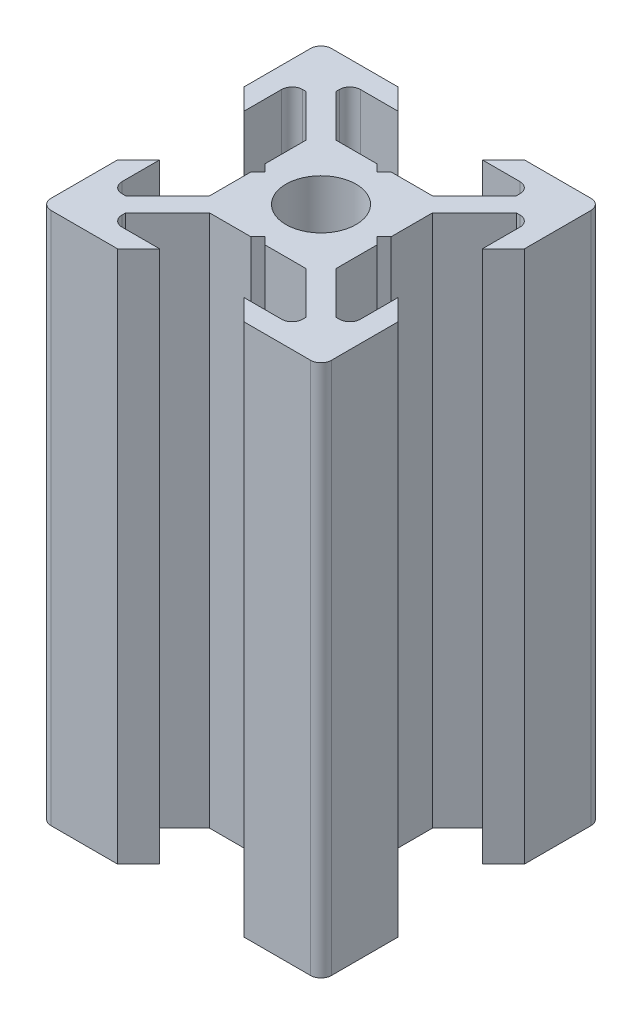
from build123d import *

# Parameters (mm, degrees)
ESQUISSE1_R      = 2.5
EXTRUSION1_DEPTH = 38
CONG_1_R         = 0.75


with BuildPart() as part:
    # Esquisse1 → Extrusion1 (new body)
    with BuildSketch(Plane(origin=(0, 0, 0), x_dir=(1, 0, 0), z_dir=(0, 1, 0))):
        Polygon((0, 4), (-0.5, 4.5), (-3.439339828, 4.5), (-6.439339828, 7.5), (-6.439339828, 8.5), (-3, 8.5), (-4.5, 10), (-10, 10), (-10, 4.5), (-8.5, 3), (-8.5, 6.439339828), (-7.5, 6.439339828), (-4.5, 3.439339828), (-4.5, 0.5), (-4, 0), (-4.5, -0.5), (-4.5, -3.439339828), (-7.5, -6.439339828), (-8.5, -6.439339828), (-8.5, -3), (-10, -4.5), (-10, -10), (-4.5, -10), (-3, -8.5), (-6.439339828, -8.5), (-6.439339828, -7.5), (-3.439339828, -4.5), (-0.5, -4.5), (0, -4), (0.5, -4.5), (3.439339828, -4.5), (6.439339828, -7.5), (6.439339828, -8.5), (3, -8.5), (4.5, -10), (10, -10), (10, -4.5), (8.5, -3), (8.5, -6.439339828), (7.5, -6.439339828), (4.5, -3.439339828), (4.5, -0.5), (4, 0), (4.5, 0.5), (4.5, 3.439339828), (7.5, 6.439339828), (8.5, 6.439339828), (8.5, 3), (10, 4.5), (10, 10), (4.5, 10), (3, 8.5), (6.439339828, 8.5), (6.439339828, 7.5), (3.439339828, 4.5), (0.5, 4.5), align=None)
        Circle(ESQUISSE1_R, mode=Mode.SUBTRACT)
    extrude(amount=EXTRUSION1_DEPTH)

    # Congé1
    cong_1_edges = [part.edges().sort_by_distance(p)[0] for p in [
        (6.439339828, 19, -8.5),
        (10, 19, -10),
        (8.5, 19, -6.439339828),
        (8.5, 19, 6.439339828),
        (10, 19, 10),
        (6.439339828, 19, 8.5),
        (-6.439339828, 19, 8.5),
        (-10, 19, 10),
        (-8.5, 19, 6.439339828),
        (-8.5, 19, -6.439339828),
        (-10, 19, -10),
        (-6.439339828, 19, -8.5),
    ]]
    fillet(cong_1_edges, radius=CONG_1_R)


solid = part.part
